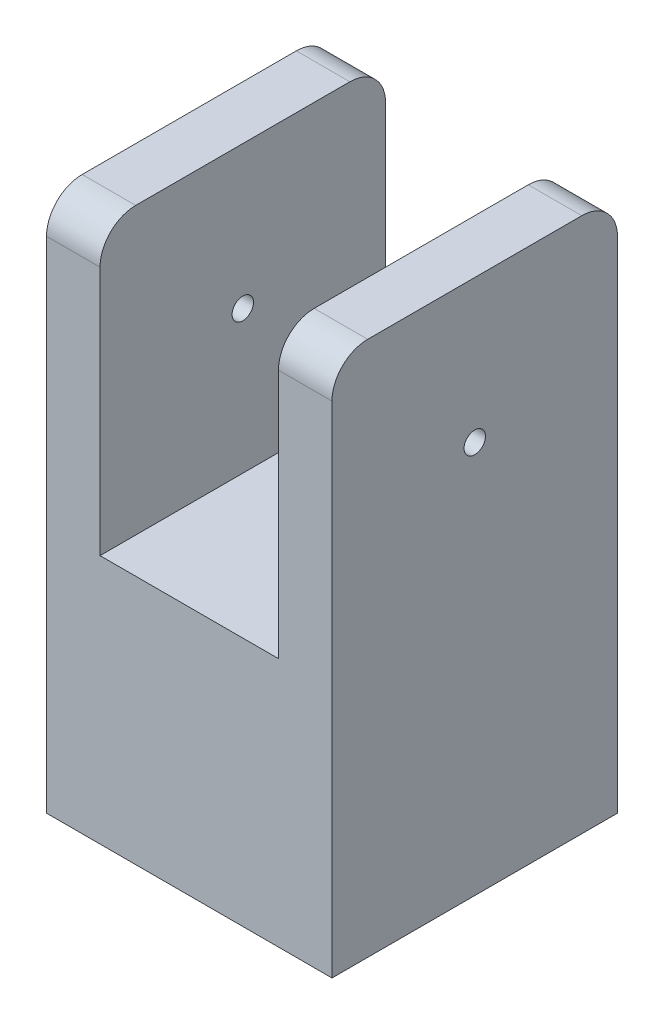
from build123d import *

# Parameters (mm, degrees)
SKETCH1_W               = 80
SKETCH1_H               = 80
SKETCH1_R               = 3
BOSS_EXTRUDE1_DEPTH     = 150
SKETCH2_W               = 50
SKETCH2_H               = 80
CUT_EXTRUDE1_DEPTH      = 80
SKETCH3_R               = 3
CUT_EXTRUDE2_DEPTH      = 1
CUT_EXTRUDE2_DEPTH_BACK = 81
FILLET1_R               = 10


with BuildPart() as part:
    # Sketch1 → Boss-Extrude1 (new body)
    with BuildSketch(Plane(origin=(0, 0, 0), x_dir=(1, 0, 0), z_dir=(0, 1, 0))):
        Rectangle(SKETCH1_W, SKETCH1_H)
        Circle(SKETCH1_R, mode=Mode.SUBTRACT)
    extrude(amount=BOSS_EXTRUDE1_DEPTH)

    # Sketch2 → Cut-Extrude1 (cut)
    with BuildSketch(Plane(origin=(0, 150, 0), x_dir=(1, 0, 0), z_dir=(0, 1, 0))):
        Rectangle(SKETCH2_W, SKETCH2_H)
    extrude(amount=-CUT_EXTRUDE1_DEPTH, mode=Mode.SUBTRACT)

    # Sketch3 → Cut-Extrude2 (cut, two sides)
    with BuildSketch(Plane(origin=(40, 0, 0), x_dir=(0, 0, -1), z_dir=(1, 0, 0))) as cut_extrude2_sk:
        with Locations((0, 110)):
            Circle(SKETCH3_R)
    extrude(amount=CUT_EXTRUDE2_DEPTH, mode=Mode.SUBTRACT)
    extrude(cut_extrude2_sk.sketch, amount=-CUT_EXTRUDE2_DEPTH_BACK, mode=Mode.SUBTRACT)

    # Fillet1
    fillet1_edges = [part.edges().sort_by_distance(p)[0] for p in [
        (-32.5, 150, 40),
        (32.5, 150, 40),
        (-32.5, 150, -40),
        (32.5, 150, -40),
    ]]
    fillet(fillet1_edges, radius=FILLET1_R)


solid = part.part
